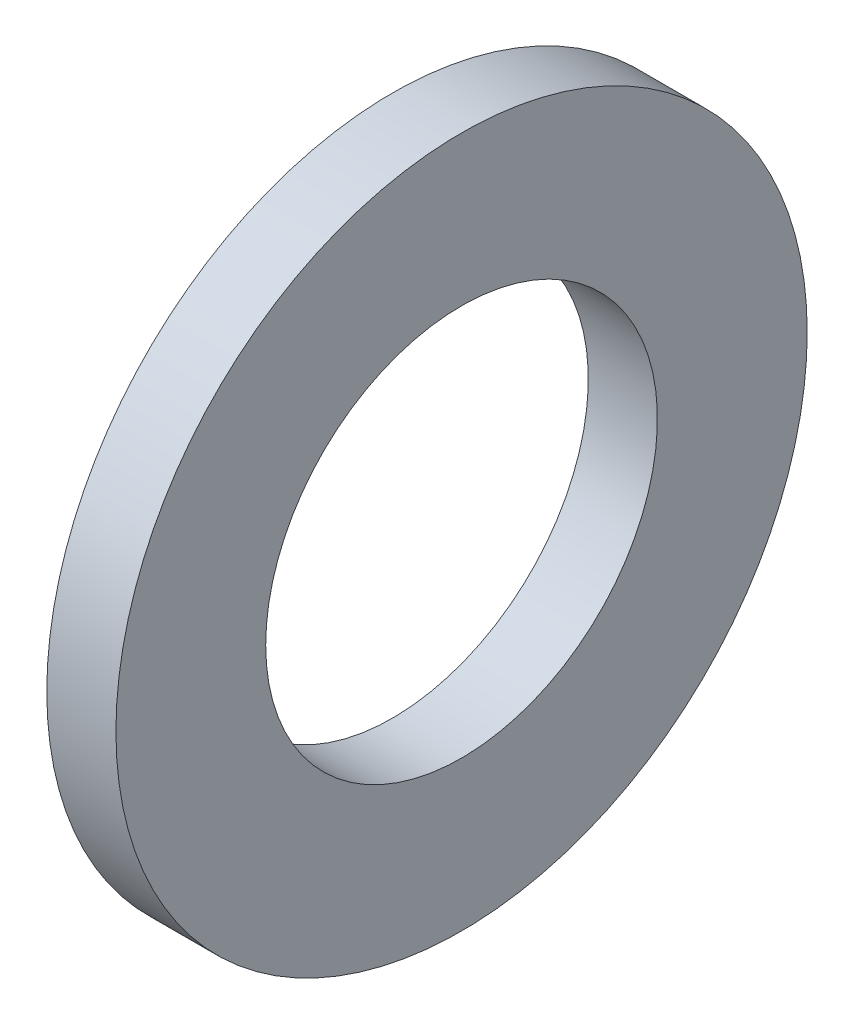
from build123d import *

# Parameters (mm, degrees)
SKETCH1_W = 3
SKETCH1_H = 6.5


with BuildPart() as part:
    # Sketch1 → Base-Revolve (revolve)
    with BuildSketch(Plane.XY):
        with Locations((-1.5, 11.75)):
            Rectangle(SKETCH1_W, SKETCH1_H)
    revolve(axis=Axis((-34.925, 0, 0), (1, 0, 0)))


solid = part.part
